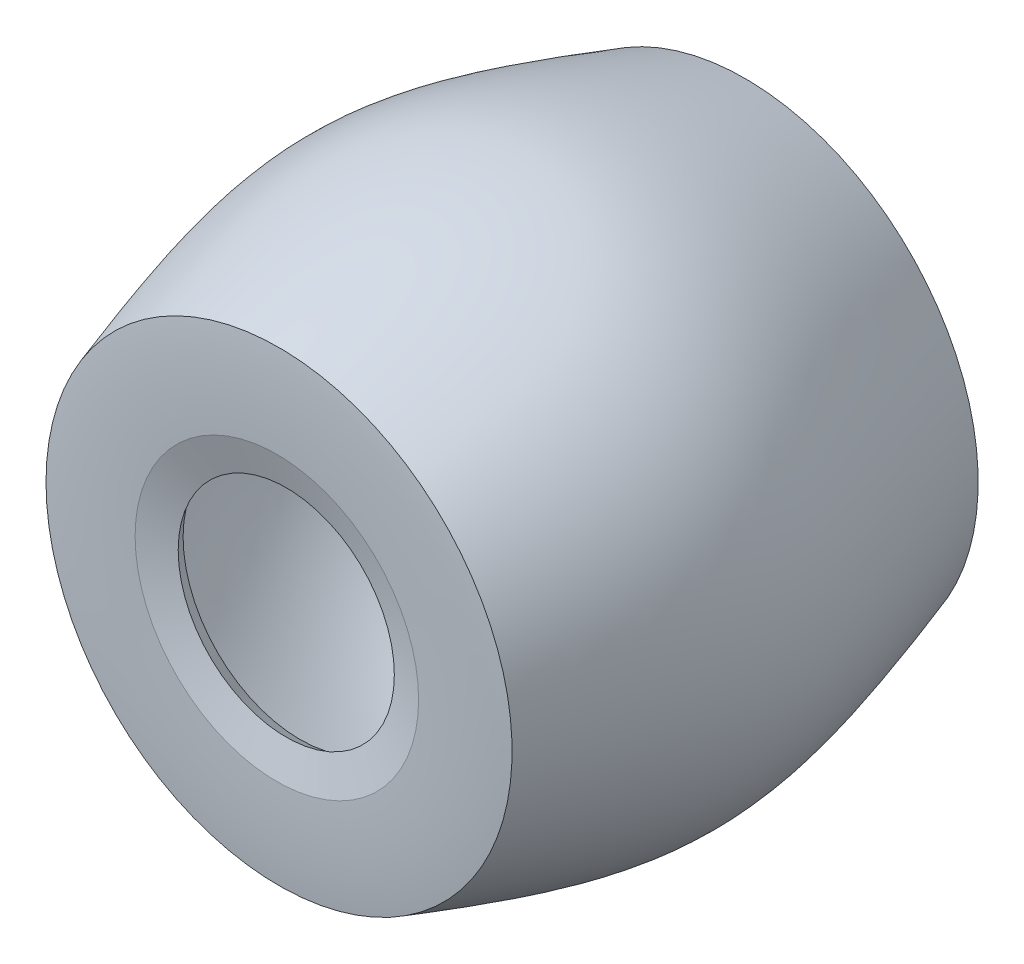
from build123d import *


with BuildPart() as part:
    # Sketch1 → Revolve1 (revolve)
    with BuildSketch(Plane(origin=(0, 0, 0), x_dir=(0, 0, -1), z_dir=(1, 0, 0))):
        with BuildLine():
            Line((-50.470077562, 30.411993884), (-48.449762995, 23.187851833))
            Line((-48.449762995, 23.187851833), (-45.48586414, 25.101449815))
            add(Edge.make_bspline(
                [(-48.449762995, 29.987422205), (-45.48586414, 25.101449815)],
                knots=[0, 0, 1, 1], degree=1))
            Line((-48.449762995, 29.987422205), (-48.449762995, 45.246394502))
            add(Edge.make_bspline(
                [(-48.449762995, 45.246394502), (-47.757317605, 45.472213508), (-46.35900942, 45.926672767), (-43.664040744, 46.795537761), (-40.409694064, 47.830094642), (-36.698146611, 48.98157899), (-31.983562013, 50.399456097), (-26.503127038, 51.950356049), (-20.489517686, 53.458887096), (-14.940594209, 54.61890372), (-8.022237241, 55.709950303), (-1.75e-07, 56.243893826), (8.022236964, 55.709949788), (14.940594045, 54.618902886), (20.489517621, 53.458886102), (26.503127078, 51.950355008), (31.983562139, 50.399455141), (36.698146804, 48.981578194), (40.409694306, 47.830094016), (43.664041026, 46.795537322), (46.359009733, 45.926672506), (47.757317932, 45.472213347), (48.449763331, 45.246394393)],
                knots=[0, 0, 0, 0, 0.015625, 0.03125, 0.0625, 0.09375, 0.125, 0.1875, 0.25, 0.3125, 0.375, 0.5, 0.625, 0.6875, 0.75, 0.8125, 0.875, 0.90625, 0.9375, 0.96875, 0.984375, 1, 1, 1, 1], degree=3))
            Line((48.449763331, 45.246394393), (48.449762995, 29.987422205))
            add(Edge.make_bspline(
                [(48.449762995, 29.987422205), (45.48586414, 25.101449815)],
                knots=[0, 0, 1, 1], degree=1))
            Line((45.48586414, 25.101449815), (48.449762995, 23.187851833))
            Line((48.449762995, 23.187851833), (50.470077562, 30.411993884))
            add(Edge.make_bspline(
                [(50.470077562, 30.411993884), (50.866201642, 41.503468145), (50, 50)],
                knots=[0, 0, 0, 1, 1, 1], degree=2))
            add(Edge.make_bspline(
                [(-50, 50), (-4.902570045, 64.707090179), (4.902570045, 64.707086659), (50, 50)],
                knots=[0, 0, 0, 0, 1, 1, 1, 1], degree=3))
            add(Edge.make_bspline(
                [(-50.470077562, 30.411993884), (-50.866201642, 41.503468145), (-50, 50)],
                knots=[0, 0, 0, 1, 1, 1], degree=2))
        make_face()
    revolve(axis=Axis((0, 0, -45.444553904), (0, 0, 1)))


solid = part.part
